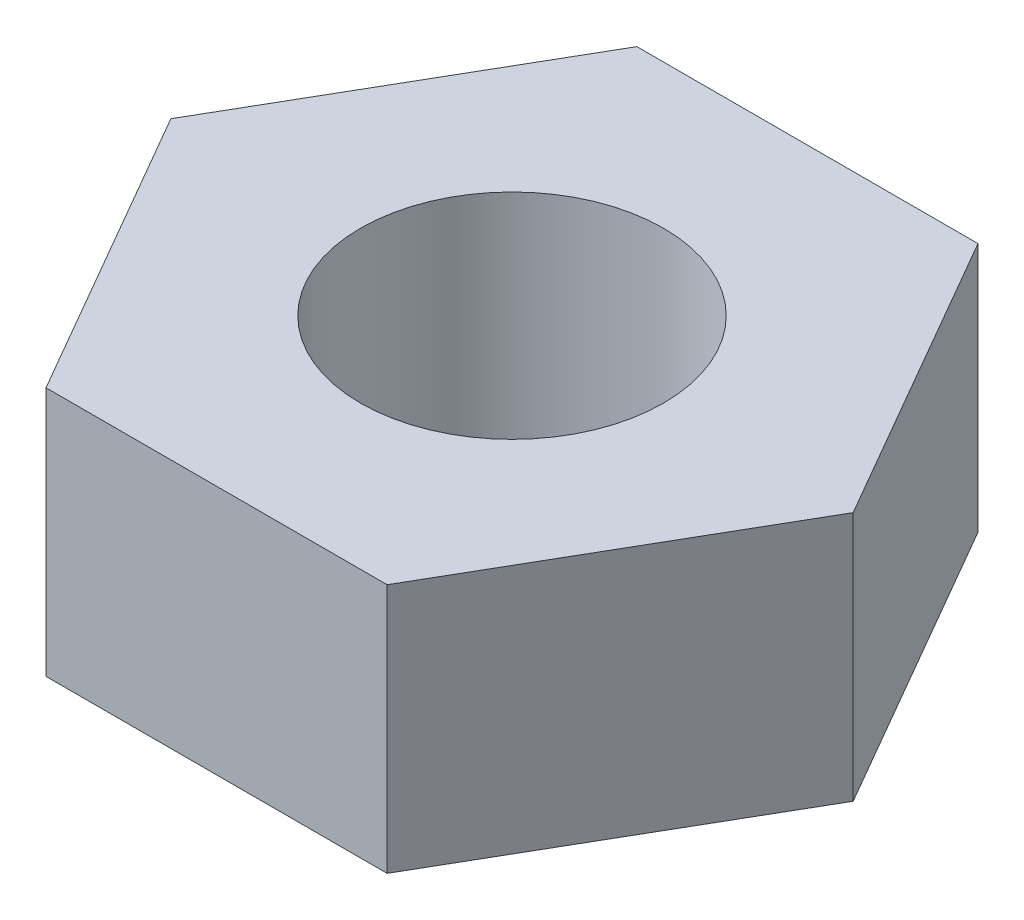
from build123d import *

# Parameters (mm, degrees)
SKETCH1_R           = 1
BOSS_EXTRUDE1_DEPTH = 1.65


with BuildPart() as part:
    # Sketch1 → Boss-Extrude1 (new body)
    with BuildSketch(Plane(origin=(0, 0, 0), x_dir=(1, 0, 0), z_dir=(0, 1, 0))):
        Polygon((2.25166605, 0), (1.125833025, 1.95), (-1.125833025, 1.95), (-2.25166605, 0), (-1.125833025, -1.95), (1.125833025, -1.95), align=None)
        Circle(SKETCH1_R, mode=Mode.SUBTRACT)
    extrude(amount=BOSS_EXTRUDE1_DEPTH)


solid = part.part
